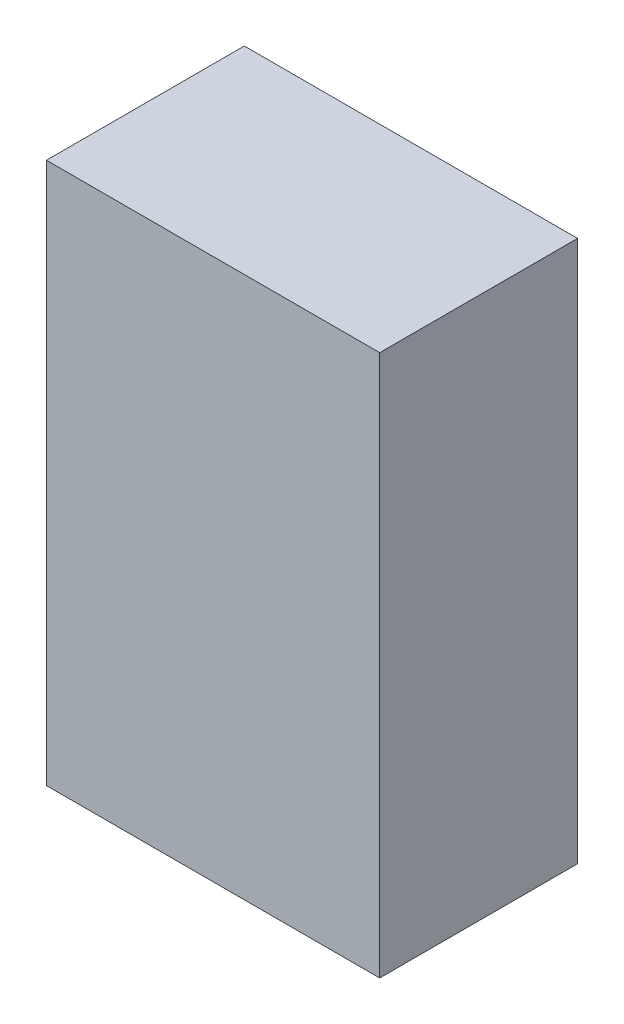
from build123d import *

# Parameters (mm, degrees)
SKETCH1_W           = 32
SKETCH1_H           = 52
BOSS_EXTRUDE1_DEPTH = 19


with BuildPart() as part:
    # Sketch1 → Boss-Extrude1 (new body)
    with BuildSketch(Plane.XY):
        with Locations((16, -26)):
            Rectangle(SKETCH1_W, SKETCH1_H)
    extrude(amount=BOSS_EXTRUDE1_DEPTH)


solid = part.part
